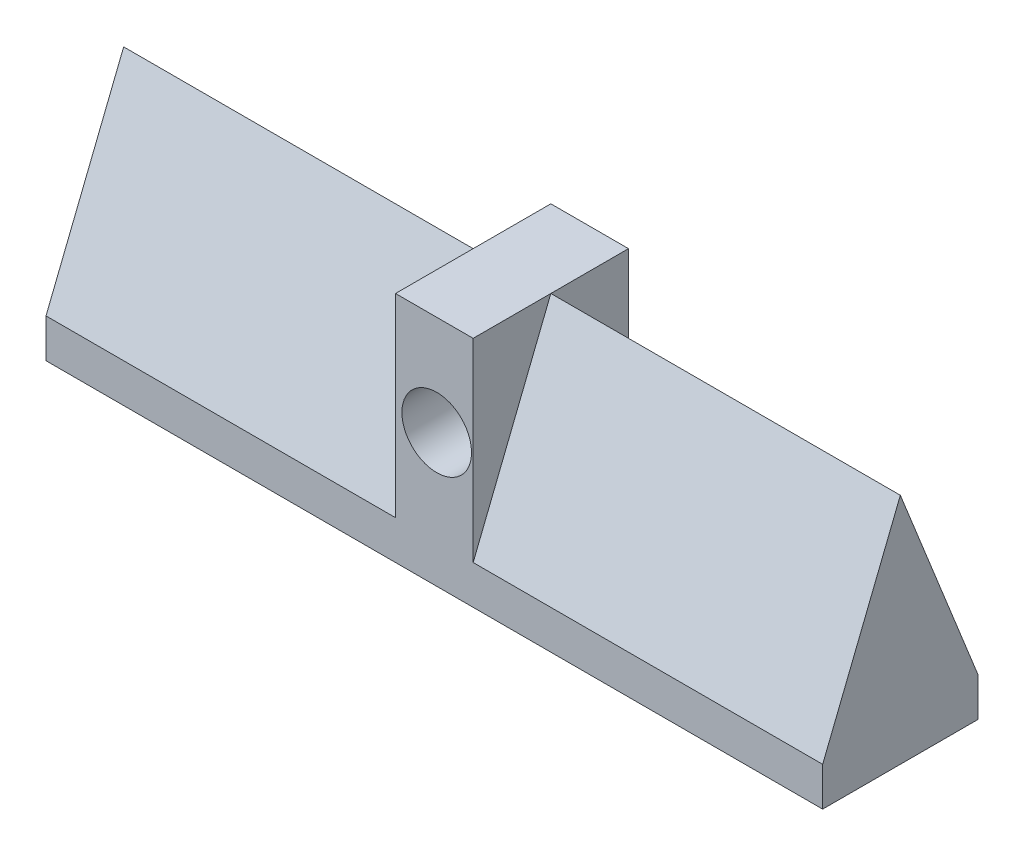
from build123d import *

# Parameters (mm, degrees)
BOSS_EXTRUDE1_DEPTH     = 1000
SKETCH2_W               = 100
SKETCH2_H               = 300
BOSS_EXTRUDE2_DEPTH     = 200
SKETCH3_R               = 44.830840268
CUT_EXTRUDE1_DEPTH      = 1
CUT_EXTRUDE1_DEPTH_BACK = 201


with BuildPart() as part:
    # Sketch1 → Boss-Extrude1 (new body)
    with BuildSketch(Plane(origin=(0, 0, 0), x_dir=(0, 0, -1), z_dir=(1, 0, 0))):
        Polygon((0, 0), (-200, 0), (-200, 50), (-100, 300), (0, 50), align=None)
    extrude(amount=BOSS_EXTRUDE1_DEPTH)

    # Sketch2 → Boss-Extrude2 (add)
    with BuildSketch(Plane(origin=(0, 0, 0), x_dir=(-1, 0, 0), z_dir=(0, 0, -1))):
        with Locations((-500, 150)):
            Rectangle(SKETCH2_W, SKETCH2_H)
    extrude(amount=-BOSS_EXTRUDE2_DEPTH)

    # Sketch3 → Cut-Extrude1 (cut, two sides)
    with BuildSketch(Plane(origin=(0, 0, 0), x_dir=(-1, 0, 0), z_dir=(0, 0, -1))) as cut_extrude1_sk:
        with Locations((-503.081055297, 171.556016762)):
            Circle(SKETCH3_R)
    extrude(amount=CUT_EXTRUDE1_DEPTH, mode=Mode.SUBTRACT)
    extrude(cut_extrude1_sk.sketch, amount=-CUT_EXTRUDE1_DEPTH_BACK, mode=Mode.SUBTRACT)


solid = part.part
